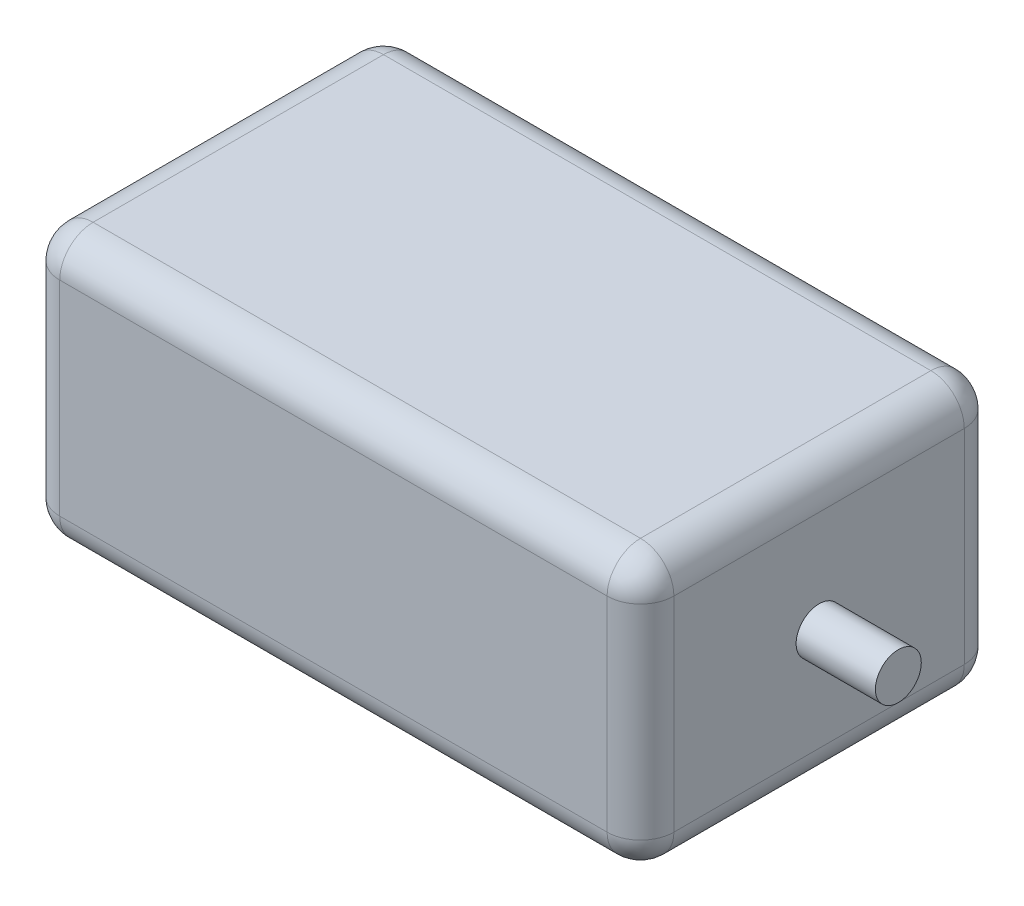
from build123d import *

# Parameters (mm, degrees)
SKETCH1_W           = 73.6
SKETCH1_H           = 42.8
BOSS_EXTRUDE1_DEPTH = 32.5
SKETCH2_R           = 2.75
BOSS_EXTRUDE2_DEPTH = 9.5
FILLET1_R           = 4


with BuildPart() as part:
    # Sketch1 → Boss-Extrude1 (new body)
    with BuildSketch(Plane(origin=(0, 0, 0), x_dir=(1, 0, 0), z_dir=(0, 1, 0))):
        with Locations((3.258713578, 0)):
            Rectangle(SKETCH1_W, SKETCH1_H)
    extrude(amount=BOSS_EXTRUDE1_DEPTH)

    # Sketch2 → Boss-Extrude2 (add)
    with BuildSketch(Plane(origin=(40.058713578, 0, 0), x_dir=(0, 0, -1), z_dir=(1, 0, 0))):
        with Locations((0, 16.25)):
            Circle(SKETCH2_R)
    extrude(amount=BOSS_EXTRUDE2_DEPTH)

    # Fillet1
    fillet1_edges = [part.edges().sort_by_distance(p)[0] for p in [
        (-33.541286422, 32.5, 0),
        (3.258713578, 32.5, 21.4),
        (40.058713578, 32.5, 0),
        (3.258713578, 0, 21.4),
        (-33.541286422, 0, 0),
        (3.258713578, 0, -21.4),
        (40.058713578, 0, 0),
        (40.058713578, 16.25, 21.4),
        (-33.541286422, 16.25, 21.4),
        (-33.541286422, 16.25, -21.4),
        (40.058713578, 16.25, -21.4),
        (3.258713578, 32.5, -21.4),
    ]]
    fillet(fillet1_edges, radius=FILLET1_R)


solid = part.part
